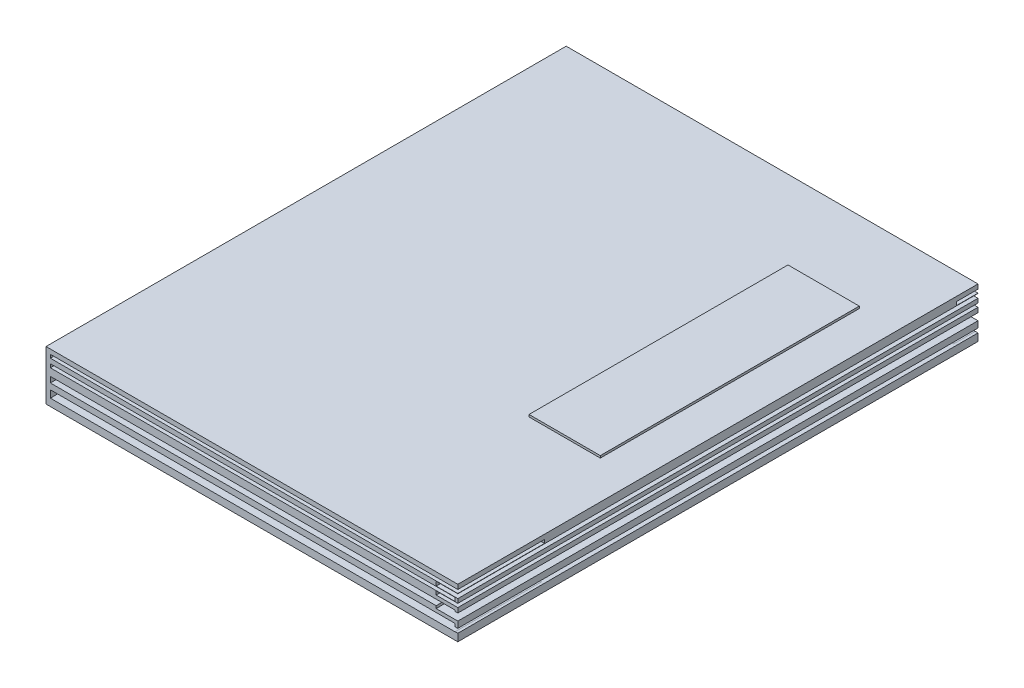
from build123d import *

# Parameters (mm, degrees)
SKETCH_1_W          = 190
SKETCH_1_H          = 240
EXTRUDE_1_DEPTH     = 23
SKETCH_2_W          = 244.953894582
SKETCH_2_H          = 1.92087839
SKETCH_2_W_2        = 245.721377573
SKETCH_2_H_2        = 1.683754508
SKETCH_2_W_3        = 244.530855974
SKETCH_2_H_3        = 3.204341319
SKETCH_2_W_4        = 243.54031242
SKETCH_2_H_4        = 1.944573874
CUT_EXTRUDE_1_DEPTH = 10
SKETCH_3_W          = 187.993982421
SKETCH_3_H          = 1.571683417
SKETCH_3_W_2        = 186.752481484
SKETCH_3_H_2        = 1.663815778
SKETCH_3_H_3        = 2.618871028
SKETCH_3_H_4        = 3.346100481
CUT_EXTRUDE_2_DEPTH = 40
SKETCH_10_W         = 32.883336007
SKETCH_10_H         = 119.476120829
EXTRUDE_2_DEPTH     = 1


with BuildPart() as part:
    # 草图1 → 凸台-拉伸1 (new body)
    with BuildSketch(Plane(origin=(0, 0, 0), x_dir=(1, 0, 0), z_dir=(0, 1, 0))):
        with Locations((0, 5)):
            Rectangle(SKETCH_1_W, SKETCH_1_H)
    extrude(amount=EXTRUDE_1_DEPTH)

    # 草图2 → 切除-拉伸1 (cut)
    with BuildSketch(Plane(origin=(95, 0, 0), x_dir=(0, 0, -1), z_dir=(1, 0, 0))):
        with Locations((6.062274081, 18.228253569)):
            Rectangle(SKETCH_2_W, SKETCH_2_H)
        with Locations((6.148753652, 14.520829351)):
            Rectangle(SKETCH_2_W_2, SKETCH_2_H_2)
        with Locations((5.553492852, 9.89782934)):
            Rectangle(SKETCH_2_W_3, SKETCH_2_H_3)
        with Locations((5.313676242, 4.397346814)):
            Rectangle(SKETCH_2_W_4, SKETCH_2_H_4)
    extrude(amount=-CUT_EXTRUDE_1_DEPTH, mode=Mode.SUBTRACT)

    # 草图3 → 切除-拉伸2 (cut)
    with BuildSketch(Plane.XY.offset(115)):
        with Locations((1.003008789, 20.115789148)):
            Rectangle(SKETCH_3_W, SKETCH_3_H)
        with Locations((0.382258321, 16.316351191)):
            Rectangle(SKETCH_3_W_2, SKETCH_3_H_2)
        with Locations((0.382258321, 10.748217394)):
            Rectangle(SKETCH_3_W_2, SKETCH_3_H_3)
        with Locations((0.382258321, 5.041481802)):
            Rectangle(SKETCH_3_W_2, SKETCH_3_H_4)
    cut_extrude_2 = extrude(amount=-CUT_EXTRUDE_2_DEPTH, mode=Mode.SUBTRACT)

    # 镜向3: 切除-拉伸2 across plane
    add(cut_extrude_2.mirror(Plane.XY.offset(-20)), mode=Mode.SUBTRACT)

    # 草图10 → 凸台-拉伸2 (add)
    with BuildSketch(Plane(origin=(0, 23, 0), x_dir=(1, 0, 0), z_dir=(0, 1, 0))):
        with Locations((61.016856815, 28.018335206)):
            Rectangle(SKETCH_10_W, SKETCH_10_H)
    extrude(amount=EXTRUDE_2_DEPTH)


solid = part.part
